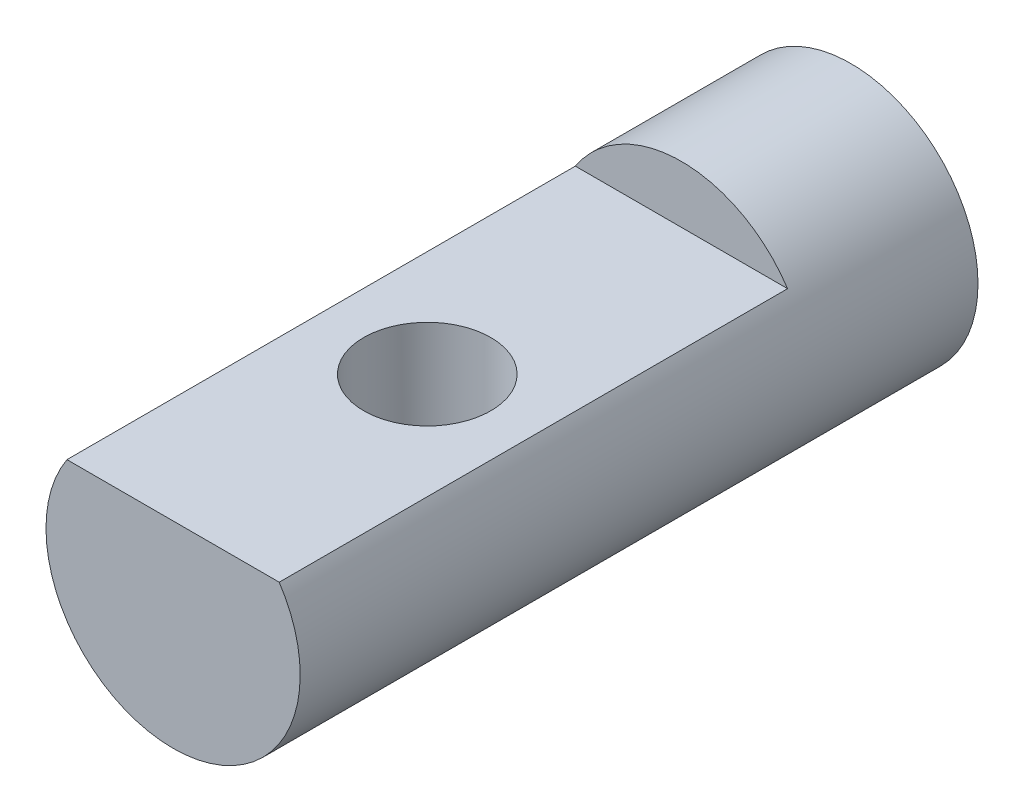
from build123d import *

# Parameters (mm, degrees)
SKETCH1_R           = 3
BOSS_EXTRUDE1_DEPTH = 16
CUT_EXTRUDE1_DEPTH  = 12
SKETCH3_R           = 1.5
CUT_EXTRUDE2_DEPTH  = 12


with BuildPart() as part:
    # Sketch1 → Boss-Extrude1 (new body)
    with BuildSketch(Plane.XY):
        Circle(SKETCH1_R)
    extrude(amount=BOSS_EXTRUDE1_DEPTH)

    # Sketch2 → Cut-Extrude1 (cut)
    with BuildSketch(Plane.XY.offset(16)):
        with BuildLine():
            Line((-2.505493963, 1.65), (2.505493963, 1.65))
            ThreePointArc((2.505493963, 1.65), (0, 3), (-2.505493963, 1.65))
        make_face()
    extrude(amount=-CUT_EXTRUDE1_DEPTH, mode=Mode.SUBTRACT)

    # Sketch3 → Cut-Extrude2 (cut)
    with BuildSketch(Plane(origin=(0, 1.65, 0), x_dir=(1, 0, 0), z_dir=(0, 1, 0))):
        with Locations((0, -10)):
            Circle(SKETCH3_R)
    extrude(amount=-CUT_EXTRUDE2_DEPTH, mode=Mode.SUBTRACT)


solid = part.part
